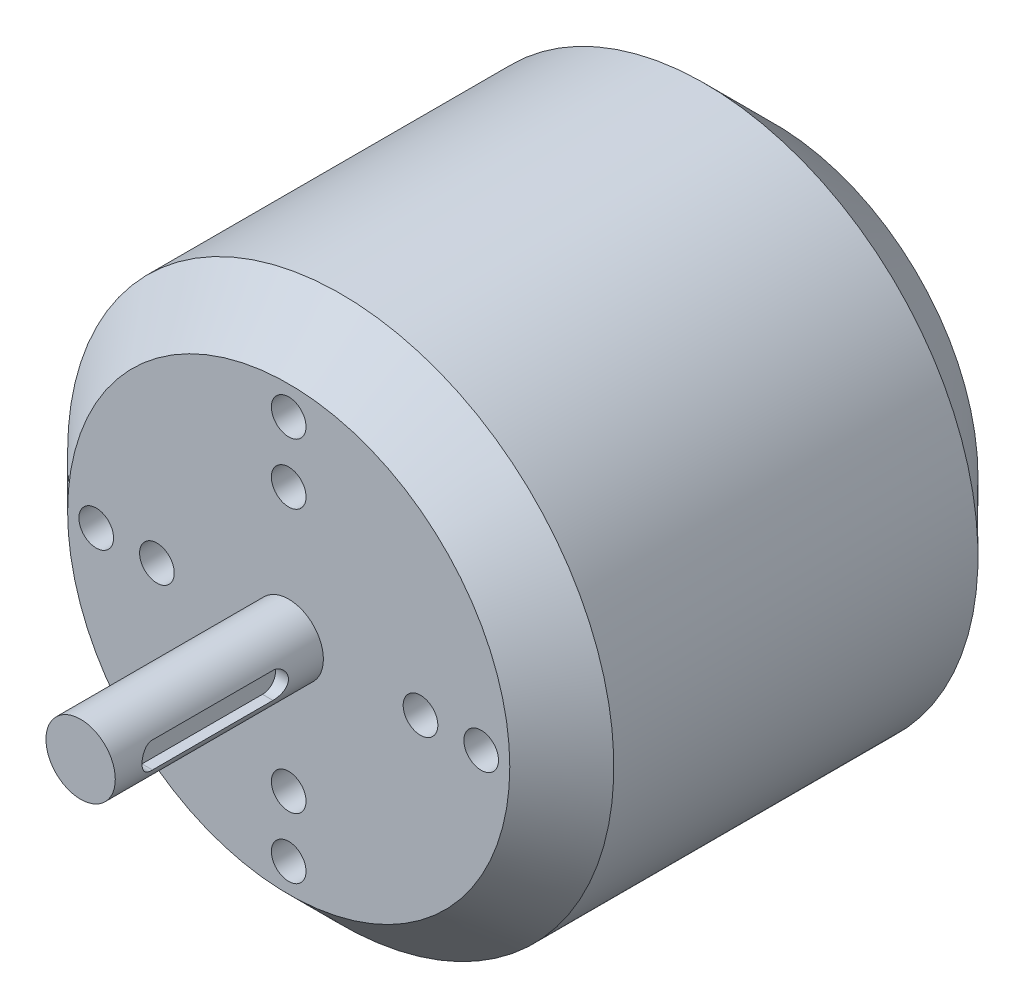
from build123d import *

# Parameters (mm, degrees)
SKETCH1_R           = 31.5
BOSS_EXTRUDE1_DEPTH = 42
SKETCH2_R           = 31.5
BOSS_EXTRUDE2_DEPTH = 6
CHAMFER1_SIZE       = 6
SKETCH4_R           = 31.5
BOSS_EXTRUDE3_DEPTH = 8
CHAMFER2_SIZE       = 8
SKETCH6_R           = 7.5
BOSS_EXTRUDE4_DEPTH = 1
SKETCH7_R           = 4
BOSS_EXTRUDE5_DEPTH = 24
SKETCH10_R          = 2
CUT_EXTRUDE4_DEPTH  = 8
CUT_EXTRUDE5_DEPTH  = 10


with BuildPart() as part:
    # Sketch1 → Boss-Extrude1 (new body)
    with BuildSketch(Plane.XY):
        with Locations(Location((0, 0, 0), (0, 0, 180))):
            Circle(SKETCH1_R)
    extrude(amount=BOSS_EXTRUDE1_DEPTH)

    # Sketch2 → Boss-Extrude2 (add)
    with BuildSketch(Plane.XY.offset(42)):
        with Locations(Location((0, 0, 0), (0, 0, 180))):
            Circle(SKETCH2_R)
    extrude(amount=BOSS_EXTRUDE2_DEPTH)

    # Chamfer1
    chamfer1_edges = [part.edges().sort_by_distance(p)[0] for p in [
        (31.5, 0, 48),
    ]]
    chamfer(chamfer1_edges, length=CHAMFER1_SIZE)

    # Sketch4 → Boss-Extrude3 (add)
    with BuildSketch(Plane(origin=(0, 0, 0), x_dir=(-1, 0, 0), z_dir=(0, 0, -1))):
        Circle(SKETCH4_R)
    extrude(amount=BOSS_EXTRUDE3_DEPTH)

    # Chamfer2
    chamfer2_edges = [part.edges().sort_by_distance(p)[0] for p in [
        (31.5, 0, -8),
    ]]
    chamfer(chamfer2_edges, length=CHAMFER2_SIZE)

    # Sketch6 → Boss-Extrude4 (add)
    with BuildSketch(Plane(origin=(0, 0, -8), x_dir=(-1, 0, 0), z_dir=(0, 0, -1))):
        Circle(SKETCH6_R)
    extrude(amount=BOSS_EXTRUDE4_DEPTH)

    # Sketch7 → Boss-Extrude5 (add)
    with BuildSketch(Plane.XY.offset(48)):
        Circle(SKETCH7_R)
    extrude(amount=BOSS_EXTRUDE5_DEPTH)

    # Sketch10 → Cut-Extrude4 (cut)
    with BuildSketch(Plane.XY.offset(48)):
        with Locations((0, 15.2)):
            Circle(SKETCH10_R)
        with Locations((0, 22.2)):
            Circle(SKETCH10_R)
        with Locations((22.2, 0)):
            Circle(SKETCH10_R)
        with Locations((15.2, 0)):
            Circle(SKETCH10_R)
        with Locations((0, -22.2)):
            Circle(SKETCH10_R)
        with Locations((0, -15.2)):
            Circle(SKETCH10_R)
        with Locations((-22.2, 0)):
            Circle(SKETCH10_R)
        with Locations((-15.2, 0)):
            Circle(SKETCH10_R)
    extrude(amount=-CUT_EXTRUDE4_DEPTH, mode=Mode.SUBTRACT)

    # Sketch11 → Cut-Extrude5 (cut)
    with BuildSketch(Plane(origin=(2.5, 0, 0), x_dir=(0, 0, -1), z_dir=(1, 0, 0))):
        with BuildLine():
            Line((-67.418537693, 1.5), (-53.527084748, 1.5))
            ThreePointArc((-53.527084748, 1.5), (-52.027084748, 0), (-53.527084748, -1.5))
            Line((-53.527084748, -1.5), (-67.418537693, -1.5))
            ThreePointArc((-67.418537693, -1.5), (-68.918537693, 0), (-67.418537693, 1.5))
        make_face()
    extrude(amount=CUT_EXTRUDE5_DEPTH, mode=Mode.SUBTRACT)


solid = part.part
